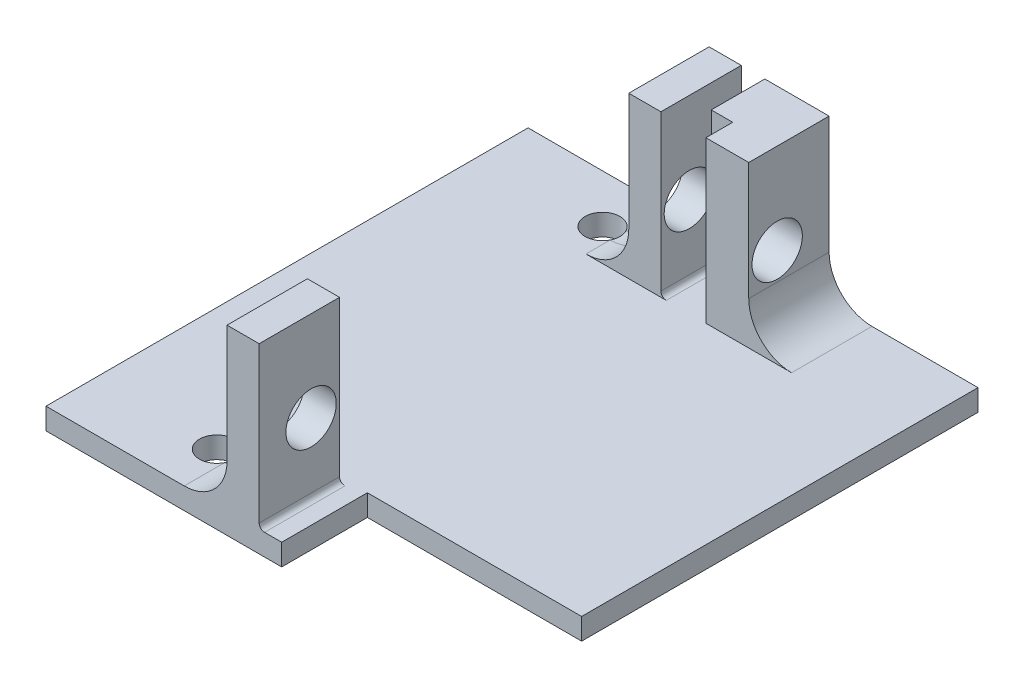
from build123d import *

# Parameters (mm, degrees)
BOSS_EXTRUDE1_DEPTH = 2
SKETCH2_W           = 3
SKETCH2_H           = 7.5
BOSS_EXTRUDE2_DEPTH = 15
CUT_EXTRUDE1_REACH  = 4
SKETCH3_R           = 1.625
SKETCH4_R           = 2.35
CUT_EXTRUDE2_DEPTH  = 26.1
FILLET1_R           = 4
FILLET2_R           = 0.5


with BuildPart() as part:
    # Sketch1 → Boss-Extrude1 (new body)
    with BuildSketch(Plane(origin=(0, 0, 0), x_dir=(1, 0, 0), z_dir=(0, 1, 0))):
        Polygon((0, 0), (0, 45), (42, 45), (42, 8), (22, 8), (22, 0), align=None)
    extrude(amount=BOSS_EXTRUDE1_DEPTH)

    # Sketch2 → Boss-Extrude2 (add)
    with BuildSketch(Plane(origin=(0, 2, 0), x_dir=(1, 0, 0), z_dir=(0, 1, 0))):
        with Locations((18.4, 41.25)):
            Rectangle(SKETCH2_W, SKETCH2_H)
        with Locations((18.4, 3.75)):
            Rectangle(SKETCH2_W, SKETCH2_H)
        Polygon((22.1, 45), (22.1, 40), (24.1, 40), (24.1, 37.5), (28.1, 37.5), (28.1, 45), align=None)
    extrude(amount=BOSS_EXTRUDE2_DEPTH)

    # Sketch3 → Cut-Extrude1 (cut, up to next)
    with BuildSketch(Plane(origin=(0, 2, 0), x_dir=(1, 0, 0), z_dir=(0, 1, 0)), mode=Mode.PRIVATE) as cut_extrude1_sk1:
        with Locations((11.45, 40.5)):
            Circle(SKETCH3_R)
    cut_extrude1_tool1 = extrude(cut_extrude1_sk1.sketch, amount=-CUT_EXTRUDE1_REACH, mode=Mode.PRIVATE) & part.part
    add(cut_extrude1_tool1.solids().sort_by_distance((11.45, 2, -40.5))[0], mode=Mode.SUBTRACT)
    # Sketch3 → Cut-Extrude1 (cut, up to next)
    with BuildSketch(Plane(origin=(0, 2, 0), x_dir=(1, 0, 0), z_dir=(0, 1, 0)), mode=Mode.PRIVATE) as cut_extrude1_sk2:
        with Locations((11.45, 4.5)):
            Circle(SKETCH3_R)
    cut_extrude1_tool2 = extrude(cut_extrude1_sk2.sketch, amount=-CUT_EXTRUDE1_REACH, mode=Mode.PRIVATE) & part.part
    add(cut_extrude1_tool2.solids().sort_by_distance((11.45, 2, -4.5))[0], mode=Mode.SUBTRACT)

    # Sketch4 → Cut-Extrude2 (cut, through all)
    with BuildSketch(Plane(origin=(16.9, 0, 0), x_dir=(0, 0, -1), z_dir=(1, 0, 0))):
        with Locations((40.155, 8.58)):
            Circle(SKETCH4_R)
        with Locations((4.845, 8.58)):
            Circle(SKETCH4_R)
    extrude(amount=CUT_EXTRUDE2_DEPTH, mode=Mode.SUBTRACT)

    # Fillet1
    fillet1_edges = [part.edges().sort_by_distance(p)[0] for p in [
        (16.9, 2, -3.75),
        (16.9, 2, -41.25),
        (28.1, 2, -41.25),
    ]]
    fillet(fillet1_edges, radius=FILLET1_R)

    # Fillet2
    fillet2_edges = [part.edges().sort_by_distance(p)[0] for p in [
        (19.9, 2, -3.75),
        (19.9, 2, -41.25),
        (22.1, 2, -42.5),
    ]]
    fillet(fillet2_edges, radius=FILLET2_R)


solid = part.part
